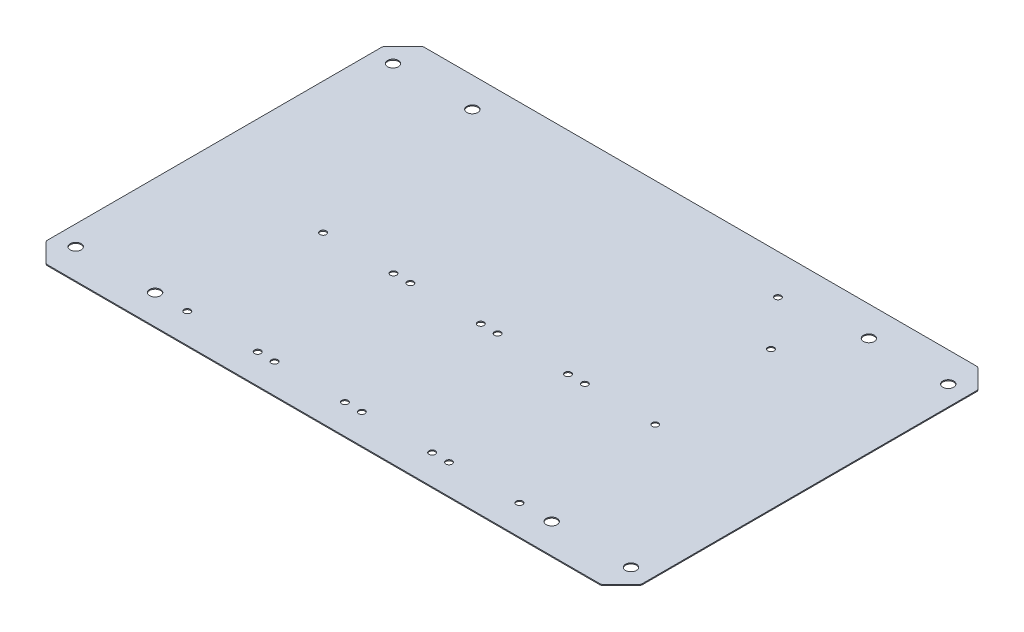
from build123d import *

# Parameters (mm, degrees)
ESQUISSE1_W                     = 300
ESQUISSE1_H                     = 190
BOSS_EXTRU_1_DEPTH              = 0.5
CHANFREIN1_SIZE                 = 10
CONG_1_R                        = 2
ESQUISSE2_R                     = 2.75
ENL_V_MAT_EXTRU_1_DEPTH         = 1.5
R_P_TITION_LIN_AIRE1_COUNT      = 2
R_P_TITION_LIN_AIRE1_PITCH      = 240
R_P_TITION_LIN_AIRE1_COUNT_DIR2 = 2
R_P_TITION_LIN_AIRE1_PITCH_DIR2 = 160
ESQUISSE3_R                     = 1.6
ENL_V_MAT_EXTRU_2_DEPTH         = 1.5
R_P_TITION_LIN_AIRE2_COUNT      = 4
R_P_TITION_LIN_AIRE2_PITCH      = 44
ESQUISSE4_R                     = 1.6
ESQUISSE4_R_2                   = 2.75
ENL_V_MAT_EXTRU_3_DEPTH         = 10


with BuildPart() as part:
    # Esquisse1 → Boss.-Extru.1 (new body)
    with BuildSketch(Plane(origin=(0, 0, 0), x_dir=(1, 0, 0), z_dir=(0, 1, 0))):
        Rectangle(ESQUISSE1_W, ESQUISSE1_H)
    extrude(amount=BOSS_EXTRU_1_DEPTH)

    # Chanfrein1
    chanfrein1_edges = [part.edges().sort_by_distance(p)[0] for p in [
        (150, 0.25, 95),
        (-150, 0.25, 95),
        (-150, 0.25, -95),
        (150, 0.25, -95),
    ]]
    chamfer(chanfrein1_edges, length=CHANFREIN1_SIZE)

    # Congé1
    cong_1_edges = [part.edges().sort_by_distance(p)[0] for p in [
        (140, 0.25, 95),
        (-140, 0.25, 95),
        (-150, 0.25, -85),
        (-150, 0.25, 85),
        (150, 0.25, -85),
        (150, 0.25, 85),
        (-140, 0.25, -95),
        (140, 0.25, -95),
    ]]
    fillet(cong_1_edges, radius=CONG_1_R)

    # Esquisse2 → Enlèv. mat.-Extru.1 (cut, through all)
    with BuildSketch(Plane.XZ):
        with Locations((-140, 80)):
            Circle(ESQUISSE2_R)
        with Locations((-100, 80)):
            Circle(ESQUISSE2_R)
    enl_v_mat_extru_1 = extrude(amount=-ENL_V_MAT_EXTRU_1_DEPTH, mode=Mode.SUBTRACT)

    # Répétition linéaire1: Enl_v. mat.-Extru.1 2 × 2
    with Locations(*[(i * R_P_TITION_LIN_AIRE1_PITCH, 0, -j * R_P_TITION_LIN_AIRE1_PITCH_DIR2) for i in range(R_P_TITION_LIN_AIRE1_COUNT) for j in range(R_P_TITION_LIN_AIRE1_COUNT_DIR2) if (i, j) != (0, 0)]):
        add(enl_v_mat_extru_1, mode=Mode.SUBTRACT)

    # Esquisse3 → Enlèv. mat.-Extru.2 (cut, through all)
    with BuildSketch(Plane(origin=(0, 0.5, 0), x_dir=(1, 0, 0), z_dir=(0, 1, 0))):
        with Locations((-83.75, -80)):
            Circle(ESQUISSE3_R)
        with Locations((-48.25, -80)):
            Circle(ESQUISSE3_R)
        with Locations((-83.75, -11.5)):
            Circle(ESQUISSE3_R)
        with Locations((-48.25, -11.5)):
            Circle(ESQUISSE3_R)
    enl_v_mat_extru_2 = extrude(amount=-ENL_V_MAT_EXTRU_2_DEPTH, mode=Mode.SUBTRACT)

    # Répétition linéaire2: Enlèv. mat.-Extru.2 ×4
    with Locations(*[(i * R_P_TITION_LIN_AIRE2_PITCH, 0, 0) for i in range(1, R_P_TITION_LIN_AIRE2_COUNT)]):
        add(enl_v_mat_extru_2, mode=Mode.SUBTRACT)

    # Esquisse4 → Enlèv. mat.-Extru.3 (cut)
    with BuildSketch(Plane(origin=(0, 0.5, 0), x_dir=(1, 0, 0), z_dir=(0, 1, 0))):
        with Locations((59.1, 75)):
            Circle(ESQUISSE4_R)
        with Locations((80, 50.6)):
            Circle(ESQUISSE4_R)
        with Locations((100, 80)):
            Circle(ESQUISSE4_R_2)
    extrude(amount=-ENL_V_MAT_EXTRU_3_DEPTH, mode=Mode.SUBTRACT)


solid = part.part
